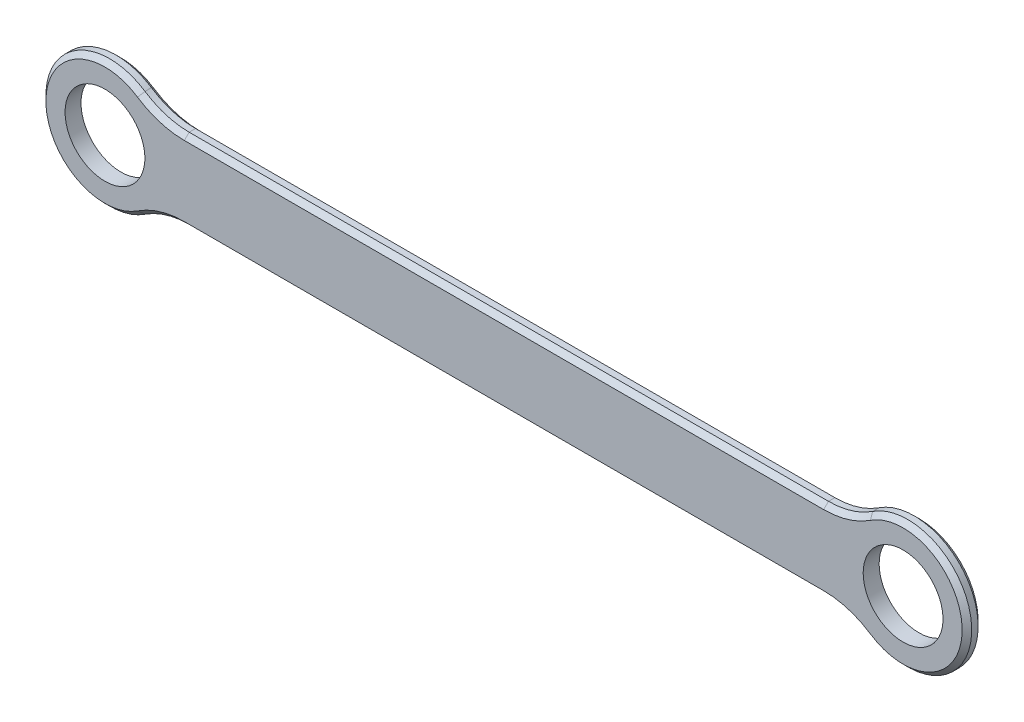
from build123d import *

# Parameters (mm, degrees)
BOSS_EXTRUDE1_DEPTH     = 0.1
FILLET1_R               = 0.5
FILLET2_R               = 0.5
CHAMFER2_SIZE           = 0.03
CHAMFER3_SIZE           = 0.03
SKETCH3_R               = 0.25
CUT_EXTRUDE1_DEPTH      = 1
CUT_EXTRUDE1_DEPTH_BACK = 1.1


with BuildPart() as part:
    # Sketch2 → Boss-Extrude1 (new body)
    with BuildSketch(Plane.XY):
        with BuildLine():
            Line((2.162109074, 0.042307692), (-2.213391126, 0.042307692))
            ThreePointArc((-2.213391126, 0.042307692), (-2.925641026, -0.207692308), (-2.213391126, -0.457692308))
            Line((-2.213391126, -0.457692308), (2.162109074, -0.457692308))
            ThreePointArc((2.162109074, -0.457692308), (2.874358974, -0.207692308), (2.162109074, 0.042307692))
        make_face()
    extrude(amount=BOSS_EXTRUDE1_DEPTH)

    # Fillet1
    fillet1_edges = [part.edges().sort_by_distance(p)[0] for p in [
        (2.162109074, 0.042307692, 0.05),
    ]]
    fillet(fillet1_edges, radius=FILLET1_R)

    # Fillet2
    fillet2_edges = [part.edges().sort_by_distance(p)[0] for p in [
        (2.162109074, -0.457692308, 0.05),
        (-2.213391126, -0.457692308, 0.05),
        (-2.213391126, 0.042307692, 0.05),
    ]]
    fillet(fillet2_edges, radius=FILLET2_R)

    # Chamfer2
    chamfer2_edges = [part.edges().sort_by_distance(p)[0] for p in [
        (2.121202823, 0.063594138, 0.1),
        (-2.925641026, -0.207692308, 0.1),
        (-0.025641026, 0.042307692, 0.1),
        (-0.025641026, -0.457692308, 0.1),
        (2.874358974, -0.207692308, 0.1),
        (-2.172484874, 0.063594138, 0.1),
        (-2.172484874, -0.478978754, 0.1),
        (2.121202823, -0.478978754, 0.1),
    ]]
    chamfer(chamfer2_edges, length=CHAMFER2_SIZE)

    # Chamfer3
    chamfer3_edges = [part.edges().sort_by_distance(p)[0] for p in [
        (2.121202823, 0.063594138, 0),
        (-2.925641026, -0.207692308, 0),
        (-0.025641026, 0.042307692, 0),
        (-0.025641026, -0.457692308, 0),
        (2.874358974, -0.207692308, 0),
        (-2.172484874, 0.063594138, 0),
        (-2.172484874, -0.478978754, 0),
        (2.121202823, -0.478978754, 0),
    ]]
    chamfer(chamfer3_edges, length=CHAMFER3_SIZE)

    # Sketch3 → Cut-Extrude1 (cut, two sides)
    with BuildSketch(Plane(origin=(0, 0, 0), x_dir=(-1, 0, 0), z_dir=(0, 0, -1))) as cut_extrude1_sk:
        with Locations((-2.474358974, -0.207692308)):
            Circle(SKETCH3_R)
        with Locations((2.525641026, -0.207692308)):
            Circle(SKETCH3_R)
    extrude(amount=CUT_EXTRUDE1_DEPTH, mode=Mode.SUBTRACT)
    extrude(cut_extrude1_sk.sketch, amount=-CUT_EXTRUDE1_DEPTH_BACK, mode=Mode.SUBTRACT)


solid = part.part
